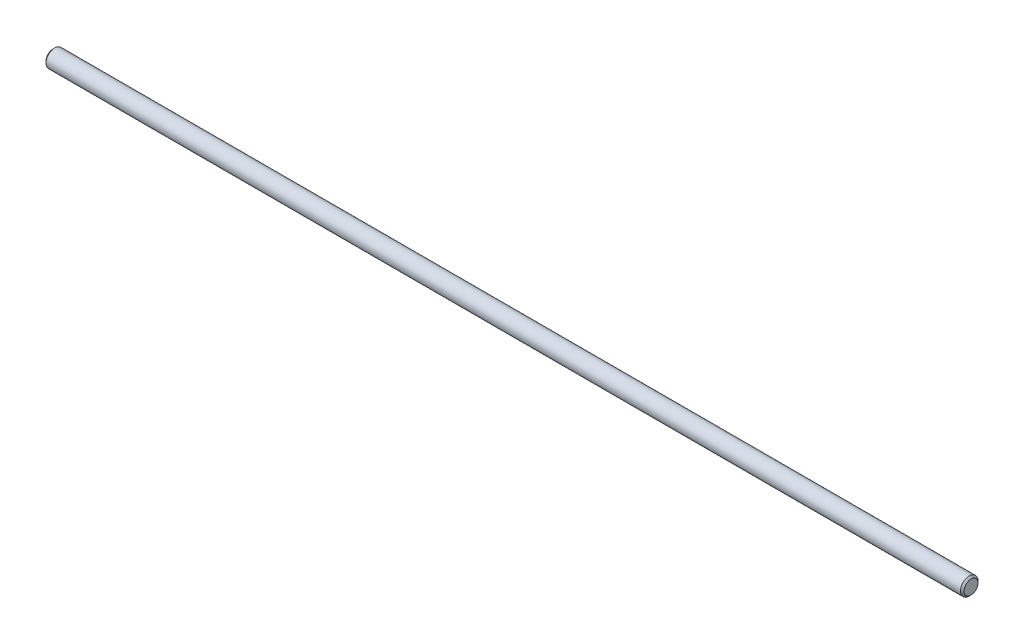
from build123d import *

# Parameters (mm, degrees)
SKETCH1_R           = 4
BOSS_EXTRUDE1_DEPTH = 210
CHAMFER1_SIZE       = 0.8


with BuildPart() as part:
    # Sketch1 → Boss-Extrude1 (new body, symmetric)
    with BuildSketch(Plane(origin=(0, 0, 0), x_dir=(0, 0, -1), z_dir=(1, 0, 0))):
        Circle(SKETCH1_R)
    extrude(amount=BOSS_EXTRUDE1_DEPTH, both=True)

    # Chamfer1
    chamfer1_edges = [part.edges().sort_by_distance(p)[0] for p in [
        (-210, 0, 4),
        (210, 0, 4),
    ]]
    chamfer(chamfer1_edges, length=CHAMFER1_SIZE)


solid = part.part
